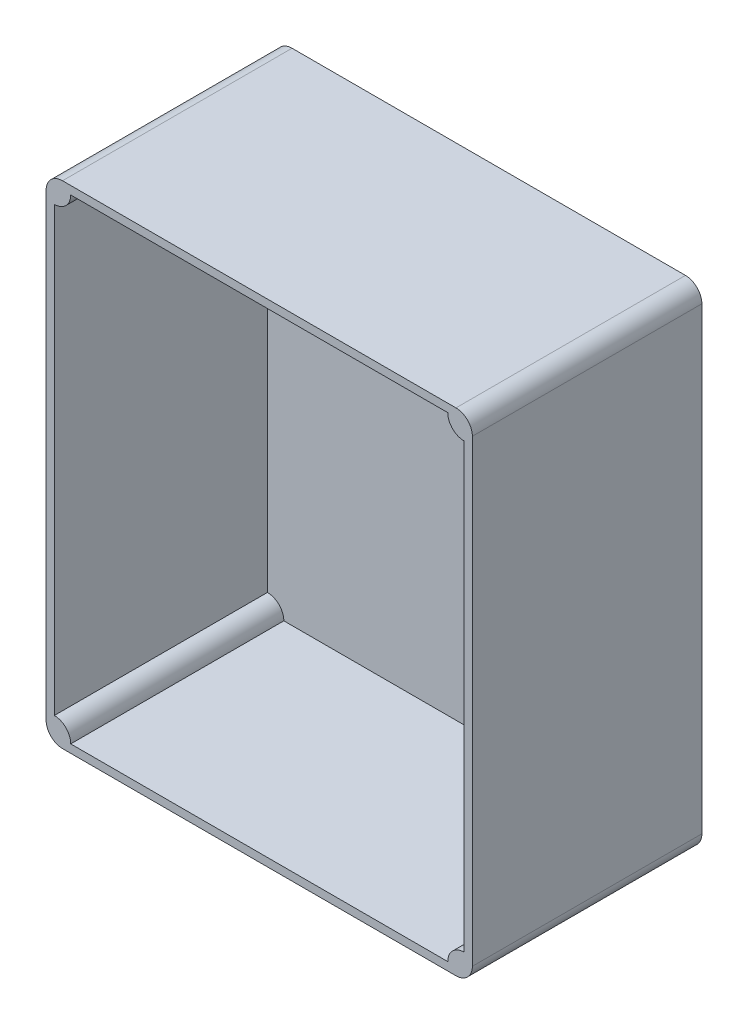
from build123d import *

# Parameters (mm, degrees)
SKETCH2_W           = 130
SKETCH2_H           = 150
BOSS_EXTRUDE2_DEPTH = 35
CUT_EXTRUDE2_DEPTH  = 65
FILLET1_R           = 5


with BuildPart() as part:
    # Sketch2 → Boss-Extrude2 (new body, symmetric)
    with BuildSketch(Plane.XY):
        Rectangle(SKETCH2_W, SKETCH2_H)
    extrude(amount=BOSS_EXTRUDE2_DEPTH, both=True)

    # Sketch3 → Cut-Extrude2 (cut)
    with BuildSketch(Plane.XY.offset(35)):
        with BuildLine():
            Line((57.5, 72.5), (-57.5, 72.5))
            ThreePointArc((-57.5, 72.5), (-58.964466094, 68.964466094), (-62.5, 67.5))
            Line((-62.5, 67.5), (-62.5, -67.5))
            ThreePointArc((-62.5, -67.5), (-58.964466094, -68.964466094), (-57.5, -72.5))
            Line((-57.5, -72.5), (57.5, -72.5))
            ThreePointArc((57.5, -72.5), (58.964466094, -68.964466094), (62.5, -67.5))
            Line((62.5, -67.5), (62.5, 67.5))
            ThreePointArc((62.5, 67.5), (58.964466094, 68.964466094), (57.5, 72.5))
        make_face()
    extrude(amount=-CUT_EXTRUDE2_DEPTH, mode=Mode.SUBTRACT)

    # Fillet1
    fillet1_edges = [part.edges().sort_by_distance(p)[0] for p in [
        (65, -75, 0),
        (-65, -75, 0),
        (-65, 75, 0),
        (65, 75, 0),
    ]]
    fillet(fillet1_edges, radius=FILLET1_R)


solid = part.part
